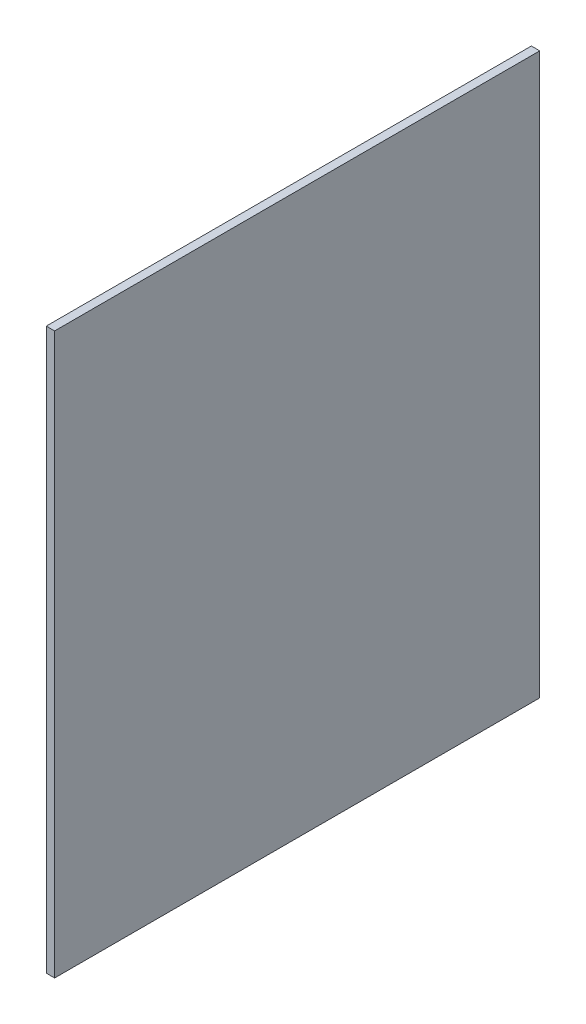
from build123d import *

# Parameters (mm, degrees)
ESQUISSE1_W        = 580
ESQUISSE1_H        = 670
BOSS_EXTRU_1_DEPTH = 10


with BuildPart() as part:
    # Esquisse1 → Boss.-Extru.1 (new body)
    with BuildSketch(Plane(origin=(0, 0, 0), x_dir=(0, 0, -1), z_dir=(1, 0, 0))):
        with Locations((188.924911197, -296.04397619)):
            Rectangle(ESQUISSE1_W, ESQUISSE1_H)
    extrude(amount=BOSS_EXTRU_1_DEPTH)


solid = part.part
